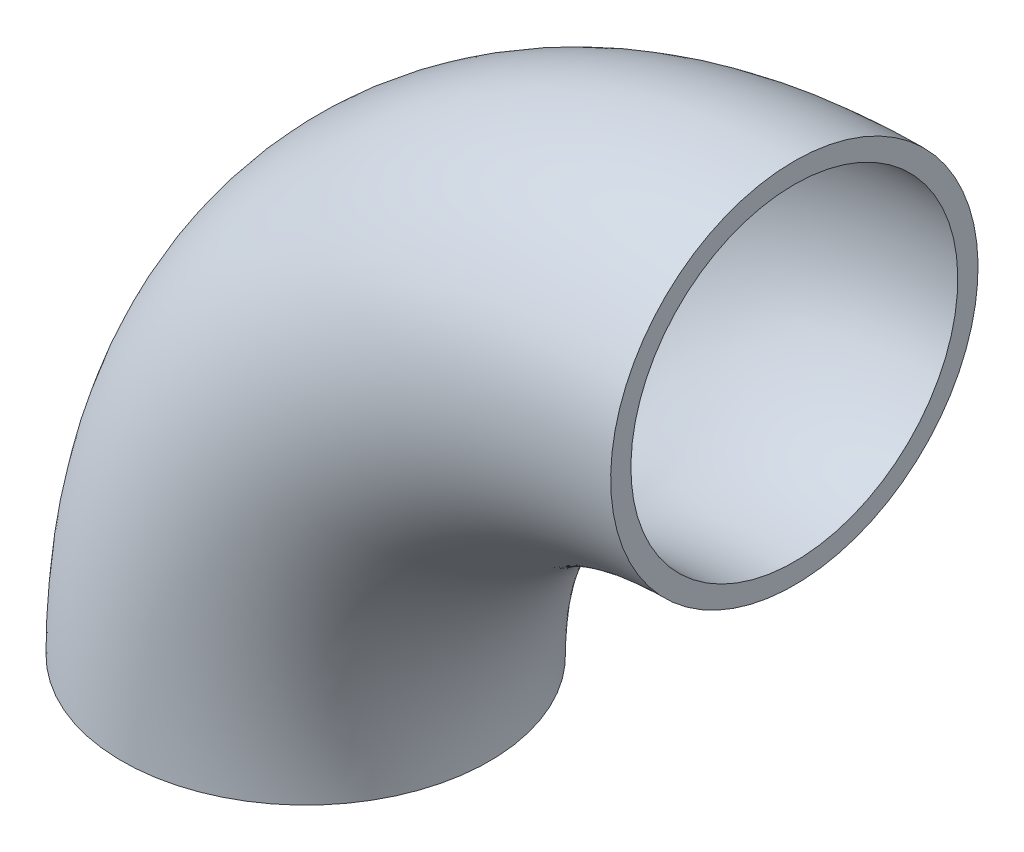
from build123d import *

# Parameters (mm, degrees)
LEITUNG_R   = 57.15
LEITUNG_R_2 = 50.85


with BuildPart() as part:
    # Austragung-D_nn1: sweep along a path in RohrBogen
    with BuildLine(Plane.XY) as austragung_d_nn1_path:
        ThreePointArc((-152, 0), (-107.48023074, 107.48023074), (0, 152))
    # Leitung → Austragung-D_nn1 (sweep)
    with BuildSketch(Plane(origin=(0, 0, 0), x_dir=(1, 0, 0), z_dir=(0, 1, 0))):
        with Locations((-152, 0)):
            Circle(LEITUNG_R)
        with Locations((-152, 0)):
            Circle(LEITUNG_R_2, mode=Mode.SUBTRACT)
    sweep(path=austragung_d_nn1_path.line)


solid = part.part
